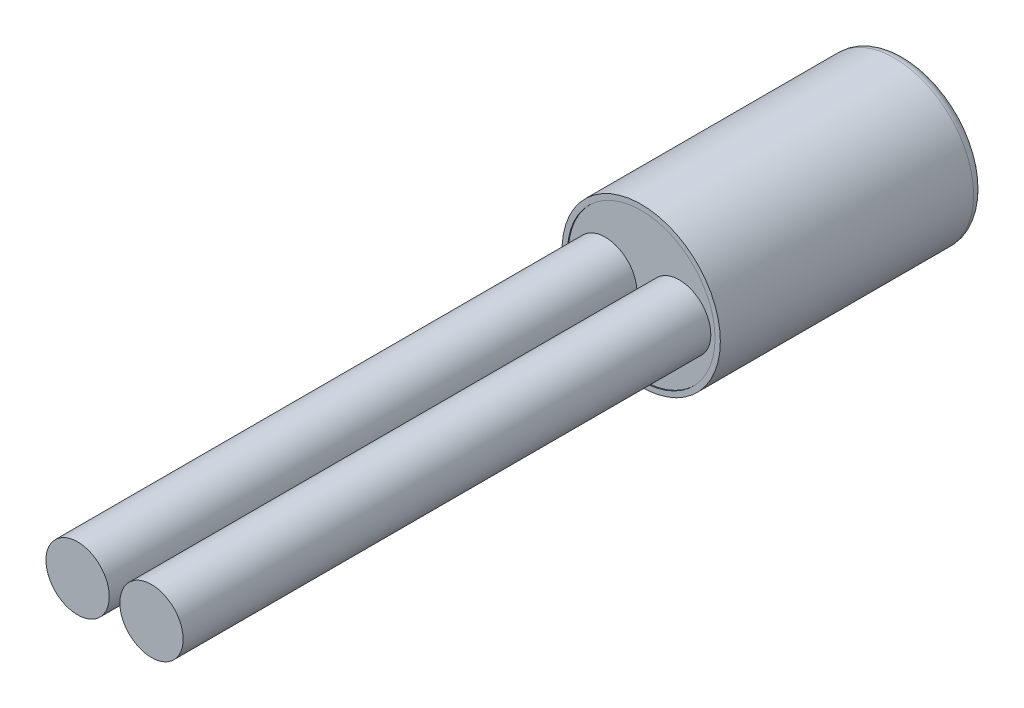
from build123d import *

# Parameters (mm, degrees)
ESQUISSE1_R             = 1.5
BOSS_EXTRU_1_DEPTH      = 5
CONG_1_R                = 0.2
ESQUISSE2_R             = 1.4
ENL_V_MAT_EXTRU_1_DEPTH = 0.02
ESQUISSE3_R             = 0.6
BOSS_EXTRU_2_DEPTH      = 10


with BuildPart() as part:
    # Esquisse1 → Boss.-Extru.1 (new body)
    with BuildSketch(Plane.XY):
        Circle(ESQUISSE1_R)
    extrude(amount=BOSS_EXTRU_1_DEPTH)

    # Congé1
    cong_1_edges = [part.edges().sort_by_distance(p)[0] for p in [
        (-1.5, 0, 0),
    ]]
    fillet(cong_1_edges, radius=CONG_1_R)

    # Esquisse2 → Enlèv. mat.-Extru.1 (cut)
    with BuildSketch(Plane.XY.offset(5)):
        Circle(ESQUISSE2_R)
    extrude(amount=-ENL_V_MAT_EXTRU_1_DEPTH, mode=Mode.SUBTRACT)

    # Esquisse3 → Boss.-Extru.2 (add)
    with BuildSketch(Plane.XY.offset(4.98)):
        with Locations((-0.7, 0)):
            Circle(ESQUISSE3_R)
        with Locations((0.7, 0)):
            Circle(ESQUISSE3_R)
    extrude(amount=BOSS_EXTRU_2_DEPTH)


solid = part.part
